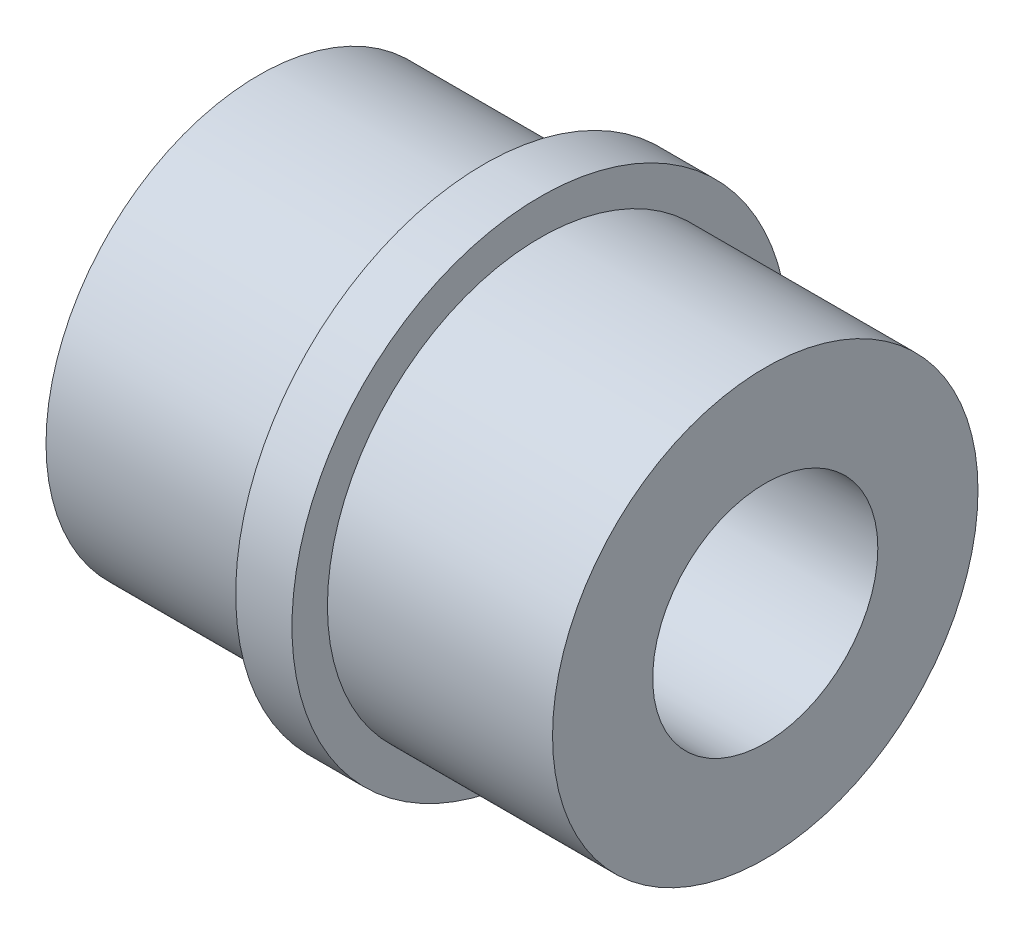
from build123d import *

# Parameters (mm, degrees)
SKETCH1_R           = 5.999999938
BOSS_EXTRUDE1_DEPTH = 6.35
SKETCH2_R           = 6.99999997
BOSS_EXTRUDE2_DEPTH = 1.5875
SKETCH3_R           = 5.999999938
BOSS_EXTRUDE3_DEPTH = 6.35
SKETCH4_R           = 3.175
CUT_EXTRUDE1_DEPTH  = 15.2875


with BuildPart() as part:
    # Sketch1 → Boss-Extrude1 (new body)
    with BuildSketch(Plane(origin=(0, 0, 0), x_dir=(0, 0, -1), z_dir=(1, 0, 0))):
        Circle(SKETCH1_R)
    extrude(amount=BOSS_EXTRUDE1_DEPTH)

    # Sketch2 → Boss-Extrude2 (add)
    with BuildSketch(Plane(origin=(6.35, 0, 0), x_dir=(0, 0, -1), z_dir=(1, 0, 0))):
        Circle(SKETCH2_R)
    extrude(amount=BOSS_EXTRUDE2_DEPTH)

    # Sketch3 → Boss-Extrude3 (add)
    with BuildSketch(Plane(origin=(7.9375, 0, 0), x_dir=(0, 0, -1), z_dir=(1, 0, 0))):
        Circle(SKETCH3_R)
    extrude(amount=BOSS_EXTRUDE3_DEPTH)

    # Sketch4 → Cut-Extrude1 (cut, through all)
    with BuildSketch(Plane(origin=(14.2875, 0, 0), x_dir=(0, 0, -1), z_dir=(1, 0, 0))):
        Circle(SKETCH4_R)
    extrude(amount=-CUT_EXTRUDE1_DEPTH, mode=Mode.SUBTRACT)


solid = part.part
